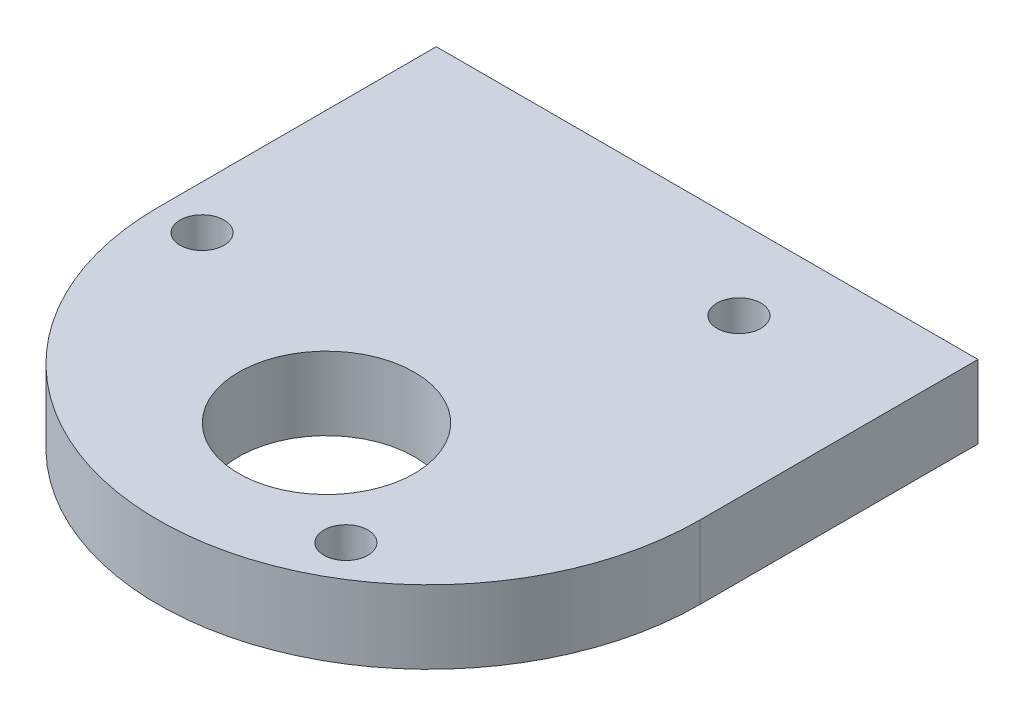
from build123d import *

# Parameters (mm, degrees)
SKETCH_1_W          = 37
SKETCH_1_H          = 5
EXTRUDE_1_DEPTH     = 19
SKETCH_2_R          = 18.5
EXTRUDE_2_DEPTH     = 5
SKETCH_3_R          = 6
SKETCH_3_R_2        = 1.5
CUT_EXTRUDE_1_DEPTH = 5
M3X0_5_1_D          = 2.5
M3X0_5_1_DEPTH      = 10
M3X0_5_1_TIP        = 0.751075774


with BuildPart() as part:
    # ｽｹｯﾁ1 → ﾎﾞｽ - 押し出し1 (new body)
    with BuildSketch(Plane.XY):
        Rectangle(SKETCH_1_W, SKETCH_1_H)
    extrude(amount=EXTRUDE_1_DEPTH)

    # ｽｹｯﾁ2 → ﾎﾞｽ - 押し出し2 (add)
    with BuildSketch(Plane.XZ.offset(2.5)):
        with Locations((0, 19)):
            Circle(SKETCH_2_R)
    extrude(amount=-EXTRUDE_2_DEPTH)

    # ｽｹｯﾁ3 → ｶｯﾄ - 押し出し1 (cut)
    with BuildSketch(Plane.XZ.offset(2.5)):
        with Locations(Location((0, 26, 0), (0, 0, 270))):  # turned: the seam where the file's is
            Circle(SKETCH_3_R)
        with Locations(Location((-15.5, 19, 0), (0, 0, 270))):  # turned: the seam where the file's is
            Circle(SKETCH_3_R_2)
        with Locations(Location((7.75, 5.576606241, 0), (0, 0, 270))):  # turned: the seam where the file's is
            Circle(SKETCH_3_R_2)
        with Locations(Location((7.75, 32.423393759, 0), (0, 0, 270))):  # turned: the seam where the file's is
            Circle(SKETCH_3_R_2)
    extrude(amount=-CUT_EXTRUDE_1_DEPTH, mode=Mode.SUBTRACT)

    # M3x0.5 ねじ穴1
    with Locations(Plane(origin=(0, 0, 0), x_dir=(-1, 0, 0), z_dir=(0, 0, -1))):
        with Locations((15, 0), (-15, 0)):
            Hole(M3X0_5_1_D / 2, depth=M3X0_5_1_DEPTH)
            with Locations((0, 0, -(M3X0_5_1_DEPTH + M3X0_5_1_TIP / 2))):  # 118° drill point
                Cone(0, M3X0_5_1_D / 2, M3X0_5_1_TIP, mode=Mode.SUBTRACT)


solid = part.part
